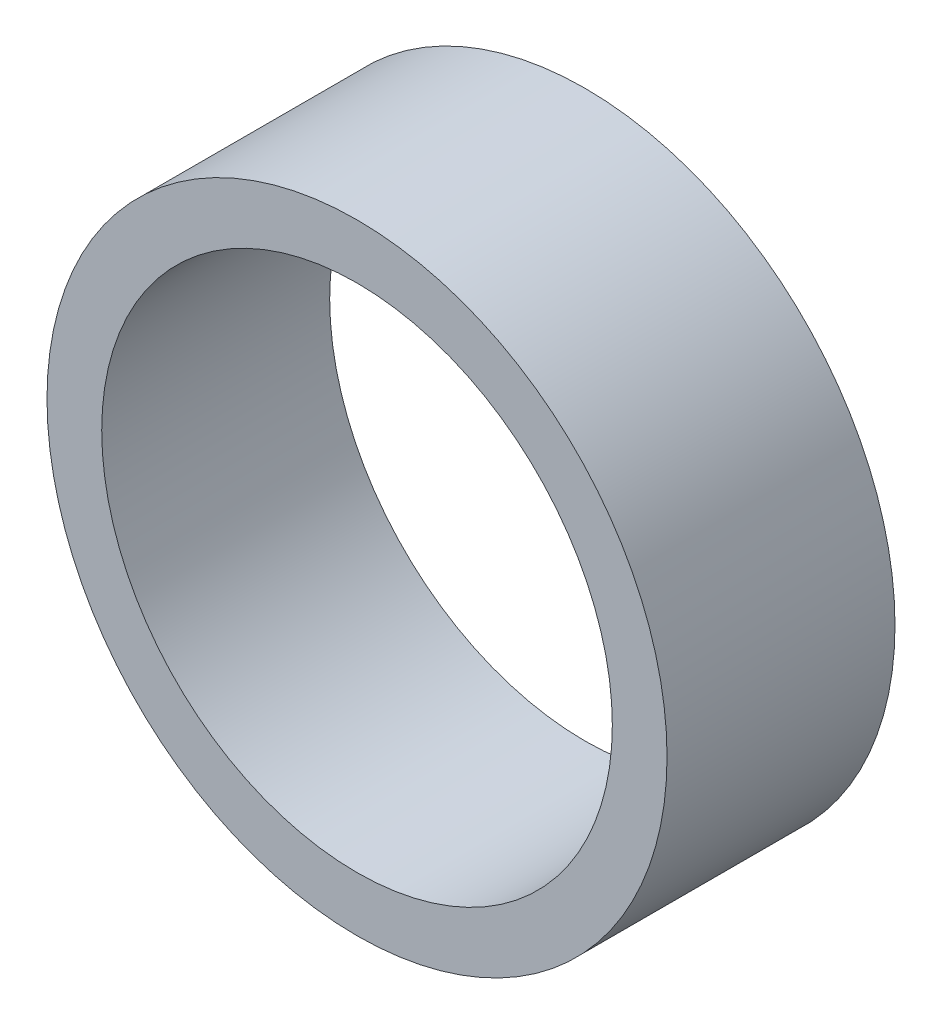
from build123d import *

# Parameters (mm, degrees)
SKETCH1_R           = 13.6
SKETCH1_R_2         = 11.2
BOSS_EXTRUDE1_DEPTH = 10


with BuildPart() as part:
    # Sketch1 → Boss-Extrude1 (new body)
    with BuildSketch(Plane.XY):
        Circle(SKETCH1_R)
        Circle(SKETCH1_R_2, mode=Mode.SUBTRACT)
    extrude(amount=BOSS_EXTRUDE1_DEPTH)


solid = part.part
